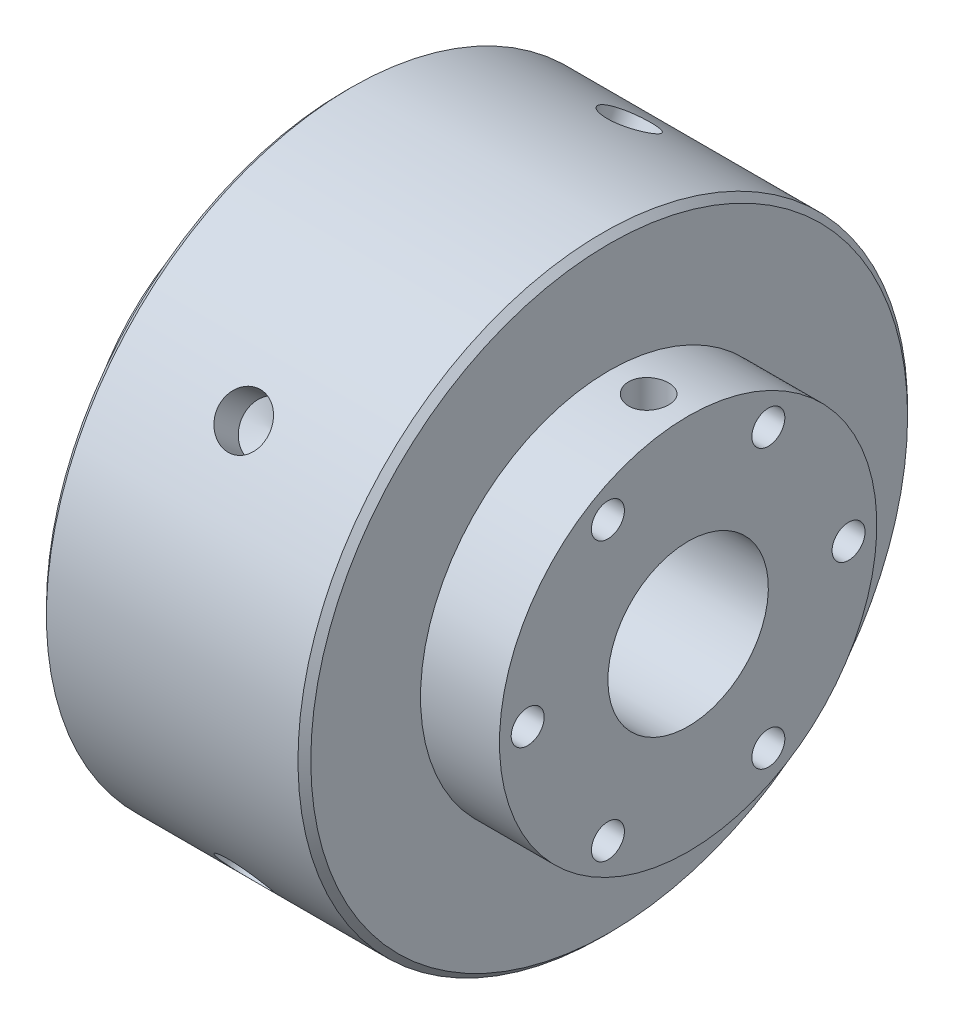
from build123d import *

# Parameters (mm, degrees)
SKETCH2_R                = 15.875
BORE_DEPTH               = 120.421470457
FACE_MOUNT_SCREWS_D      = 6.5278
SKETCH5_W                = 3.96875
SKETCH5_H                = 60.325
SET_SCREWS_AT_2_COUNT    = 2
SET_SCREWS_AT_2_PITCH    = 67.945
CHAMFER1_SIZE            = 1.27
SKETCH15_R               = 3
BOSS_EXTRUDE1_DEPTH      = 1
BOSS_EXTRUDE1_DEPTH_BACK = 30.48
SKETCH16_R               = 5
BOSS_EXTRUDE2_DEPTH      = 6
CHAMFER2_SIZE            = 0.381
CUT_EXTRUDE2_DEPTH       = 2
LPATTERN2_COUNT          = 2
LPATTERN2_PITCH          = 14.095984
LPATTERN2_2_COUNT        = 2
LPATTERN2_2_PITCH        = 14.095984
SKETCH18_R               = 37.338
SKETCH18_R_2             = 15.875
CUT_EXTRUDE3_DEPTH       = 0.0635
CIRPATTERN1_COUNT        = 4
CIRPATTERN1_ANGLE        = 240


with BuildPart() as part:
    # Sketch1 → Hub (revolve)
    with BuildSketch(Plane.XY, mode=Mode.PRIVATE) as hub_sk:
        Polygon((-26.162, 60.325), (26.162, 60.325), (26.162, 37.338), (41.783, 37.338), (41.783, 0), (-41.783, 0), (-41.783, 37.338), (-26.162, 37.338), align=None)
    revolve(hub_sk.sketch.rotate(Axis((-41.783, 0, 0), (1, 0, 0)), 180), axis=Axis((-41.783, 0, 0), (1, 0, 0)))

    # Sketch2 → Bore (cut, through all)
    with BuildSketch(Plane(origin=(41.783, 0, 0), x_dir=(0, 0, -1), z_dir=(1, 0, 0))):
        with Locations(Location((0, 0, 0), (0, 0, 90))):
            Circle(SKETCH2_R)
    extrude(amount=-BORE_DEPTH, mode=Mode.SUBTRACT)

    # Face Mount Screws (through all)
    with Locations(Plane(origin=(41.783, 0, 0), x_dir=(0, 0, -1), z_dir=(1, 0, 0))):
        with Locations((-31.75, 0), (15.875, 27.49630657), (15.875, -27.49630657), (-15.875, -27.49630657), (31.75, 0), (-15.875, 27.49630657)):
            Hole(FACE_MOUNT_SCREWS_D / 2)

    # Sketch5 → Set Screws (revolve, cut)
    with BuildSketch(Plane(origin=(-33.9725, 0, 0), x_dir=(0, 0, -1), z_dir=(1, 0, 0))):
        with Locations((1.984375, 30.1625)):
            Rectangle(SKETCH5_W, SKETCH5_H)
    set_screws = revolve(axis=Axis((-33.9725, -6.35, 0), (0, 1, 0)), mode=Mode.SUBTRACT)

    # Set Screws at 2: Set Screws ×2
    with Locations(*[(i * SET_SCREWS_AT_2_PITCH, 0, 0) for i in range(1, SET_SCREWS_AT_2_COUNT)]):
        add(set_screws, mode=Mode.SUBTRACT)

    # Chamfer1
    chamfer1_edges = [part.edges().sort_by_distance(p)[0] for p in [
        (-26.162, 60.325, 0),
        (26.162, 60.325, 0),
    ]]
    chamfer(chamfer1_edges, length=CHAMFER1_SIZE)

    # Sketch12 → Cut-Revolve1 (revolve, cut)
    with BuildSketch(Plane.XY.offset(-53.34), mode=Mode.PRIVATE) as cut_revolve1_sk:
        Polygon((-5.5, 60.325), (-5.5, 10), (-3.3, 10), (-3.3, -60.325), (0, -60.325), (0, 60.325), align=None)
    revolve(cut_revolve1_sk.sketch.rotate(Axis((0, -60.325, -53.34), (0, 1, 0)), 180), axis=Axis((0, -60.325, -53.34), (0, 1, 0)), mode=Mode.SUBTRACT)

    # Sketch14 → Cut-Revolve2 (revolve, cut)
    with BuildSketch(Plane.XY.offset(-53.34)):
        Polygon((-14.096, -60.325), (-19.596, -60.325), (-19.596, -10), (-17.396, -10), (-17.396, 60.325), (-14.096, 60.325), align=None)
    cut_revolve2 = revolve(axis=Axis((-14.096, 60.325, -53.34), (0, -1, 0)), mode=Mode.SUBTRACT)

    # Mirror2: Cut-Revolve2 across plane
    add(cut_revolve2.mirror(Plane(origin=(0, 0, 0), x_dir=(0, 0, 1), z_dir=(1, 0, 0))), mode=Mode.SUBTRACT)

    # Sketch18 → Cut-Extrude3 (cut, symmetric)
    with BuildSketch(Plane(origin=(0, 0, 0), x_dir=(0, 0, -1), z_dir=(1, 0, 0))):
        with Locations(Location((0, 0, 0), (0, 0, 270))):
            Circle(SKETCH18_R)
        with Locations(Location((0, 0, 0), (0, 0, 90))):
            Circle(SKETCH18_R_2, mode=Mode.SUBTRACT)
    extrude(amount=CUT_EXTRUDE3_DEPTH, both=True, mode=Mode.SUBTRACT)

    # Sketch19 → 25_64 _0.39063_ Diameter Hole1 (revolve, cut)
    with BuildSketch(Plane(origin=(0, -52.242982483, -30.1625), x_dir=(0, 0.499999999999998, -0.8660254037844399), z_dir=(1, 0, 0))):
        Polygon((0, 0), (0, 9.330870132), (4.961001, 6.35), (4.961001, 0), align=None)
    f_25_64_0_39063_diameter_hole1 = revolve(axis=Axis((0, -57.742243797, -33.3375), (0, 0.8660254037844398, 0.49999999999999795)), mode=Mode.SUBTRACT)

    # CirPattern1: 25_64 _0.39063_ Diameter Hole1 ×4 about axis
    cirpattern1_axis = Axis((-41.783, 0, 0), (-1, 0, 0))
    for i in range(1, CIRPATTERN1_COUNT):
        add(f_25_64_0_39063_diameter_hole1.rotate(cirpattern1_axis, i * CIRPATTERN1_ANGLE / (CIRPATTERN1_COUNT - 1)), mode=Mode.SUBTRACT)


with BuildPart() as body_2:
    # Sketch15 → Boss-Extrude1 (new, two sides)
    with BuildSketch(Plane(origin=(0, 10, 0), x_dir=(1, 0, 0), z_dir=(0, 1, 0))) as boss_extrude1_sk:
        with Locations(Location((0, 53.34, 0), (0, 0, 180))):
            Circle(SKETCH15_R)
    extrude(amount=BOSS_EXTRUDE1_DEPTH)
    extrude(boss_extrude1_sk.sketch, amount=-BOSS_EXTRUDE1_DEPTH_BACK)

    # Sketch16 → Boss-Extrude2 (add)
    with BuildSketch(Plane(origin=(0, 11, 0), x_dir=(1, 0, 0), z_dir=(0, 1, 0))):
        with Locations(Location((0, 53.34, 0), (0, 0, 180))):
            Circle(SKETCH16_R)
    extrude(amount=BOSS_EXTRUDE2_DEPTH)

    # Chamfer2
    chamfer2_edges = [body_2.edges().sort_by_distance(p)[0] for p in [
        (3, -20.48, -53.34),
        (5, 17, -53.34),
    ]]
    chamfer(chamfer2_edges, length=CHAMFER2_SIZE)

    # Sketch17 → Cut-Extrude2 (cut)
    with BuildSketch(Plane(origin=(0, 17, 0), x_dir=(1, 0, 0), z_dir=(0, 1, 0))):
        Polygon((1.443375673, 55.84), (-1.443375673, 55.84), (-2.886751346, 53.34), (-1.443375673, 50.84), (1.443375673, 50.84), (2.886751346, 53.34), align=None)
    extrude(amount=-CUT_EXTRUDE2_DEPTH, mode=Mode.SUBTRACT)


with BuildPart() as lpattern2_1:
    # LPattern2: pattern copy
    add(body_2.part.moved(Location(Vector(1, 0, 0) * (1 * LPATTERN2_PITCH))))


with BuildPart() as lpattern2_2_1:
    # LPattern2 2: pattern copy
    add(body_2.part.moved(Location(Vector(-1, 0, 0) * (1 * LPATTERN2_2_PITCH))))


with BuildPart() as body_5:
    # Mirror4: mirrored copy
    add(lpattern2_1.part.mirror(Plane.ZX))


with BuildPart() as body_6:
    # Mirror4 2: mirrored copy
    add(lpattern2_2_1.part.mirror(Plane.ZX))


solid = Compound([part.part, body_2.part, body_5.part, body_6.part])
